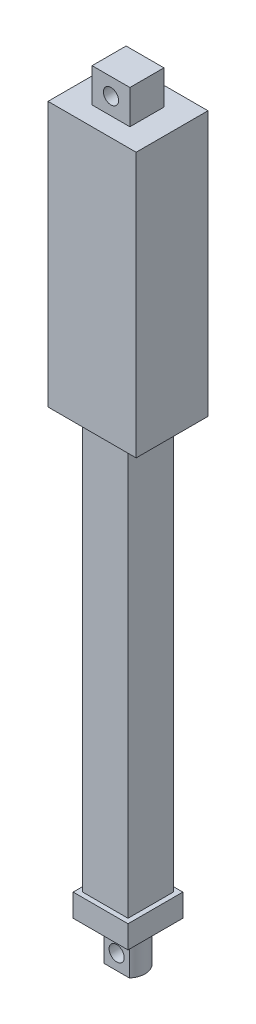
from build123d import *

# Parameters (mm, degrees)
SKETCH_1_W               = 23.3
SKETCH_1_H               = 19
EXTRUDE_1_DEPTH          = 70
SKETCH_2_W               = 10
SKETCH_2_H               = 9
EXTRUDE_2_DEPTH          = 9
SKETCH_3_R               = 2
CUT_EXTRUDE_1_DEPTH      = 6
CUT_EXTRUDE_1_DEPTH_BACK = 15
SKETCH_4_W               = 12
SKETCH_4_H               = 12
EXTRUDE_3_DEPTH          = 110
SKETCH_5_W               = 14.5
SKETCH_5_H               = 14.5
EXTRUDE_4_DEPTH          = 6
SKETCH_6_R               = 4.5
EXTRUDE_5_DEPTH          = 10.5
CUT_EXTRUDE_3_DEPTH      = 10.5
SKETCH_8_R               = 2
CUT_EXTRUDE_4_DEPTH      = 13.5


with BuildPart() as part:
    # 草图1 → 凸台-拉伸1 (new body)
    with BuildSketch(Plane(origin=(0, 0, 0), x_dir=(1, 0, 0), z_dir=(0, 1, 0))):
        Rectangle(SKETCH_1_W, SKETCH_1_H)
    extrude(amount=EXTRUDE_1_DEPTH)

    # 草图2 → 凸台-拉伸2 (add)
    with BuildSketch(Plane(origin=(0, 70, 0), x_dir=(1, 0, 0), z_dir=(0, 1, 0))):
        Rectangle(SKETCH_2_W, SKETCH_2_H)
    extrude(amount=EXTRUDE_2_DEPTH)

    # 草图3 → 切除-拉伸1 (cut, two sides)
    with BuildSketch(Plane.XY.offset(4.5)) as cut_extrude_1_sk:
        with Locations((0, 74.5)):
            Circle(SKETCH_3_R)
    extrude(amount=CUT_EXTRUDE_1_DEPTH, mode=Mode.SUBTRACT)
    extrude(cut_extrude_1_sk.sketch, amount=-CUT_EXTRUDE_1_DEPTH_BACK, mode=Mode.SUBTRACT)

    # 草图4 → 凸台-拉伸3 (add)
    with BuildSketch(Plane.XZ):
        Rectangle(SKETCH_4_W, SKETCH_4_H)
    extrude(amount=EXTRUDE_3_DEPTH)

    # 草图5 → 凸台-拉伸4 (add)
    with BuildSketch(Plane.XZ.offset(110)):
        Rectangle(SKETCH_5_W, SKETCH_5_H)
    extrude(amount=EXTRUDE_4_DEPTH)

    # 草图6 → 凸台-拉伸5 (add)
    with BuildSketch(Plane.XZ.offset(116)):
        Circle(SKETCH_6_R)
    extrude(amount=EXTRUDE_5_DEPTH)

    # 草图7 → 切除-拉伸3 (cut)
    with BuildSketch(Plane.XZ.offset(126.5)):
        with BuildLine():
            Line((-3.354101966, -3), (3.354101966, -3))
            ThreePointArc((3.354101966, -3), (0, -4.5), (-3.354101966, -3))
        make_face()
        with BuildLine():
            Line((-3.354101966, 3), (3.354101966, 3))
            ThreePointArc((3.354101966, 3), (0, 4.5), (-3.354101966, 3))
        make_face()
    extrude(amount=-CUT_EXTRUDE_3_DEPTH, mode=Mode.SUBTRACT)

    # 草图8 → 切除-拉伸4 (cut, through all)
    with BuildSketch(Plane(origin=(0, 0, -3), x_dir=(-1, 0, 0), z_dir=(0, 0, -1))):
        with Locations((0, -122.5)):
            Circle(SKETCH_8_R)
    extrude(amount=-CUT_EXTRUDE_4_DEPTH, mode=Mode.SUBTRACT)


solid = part.part
